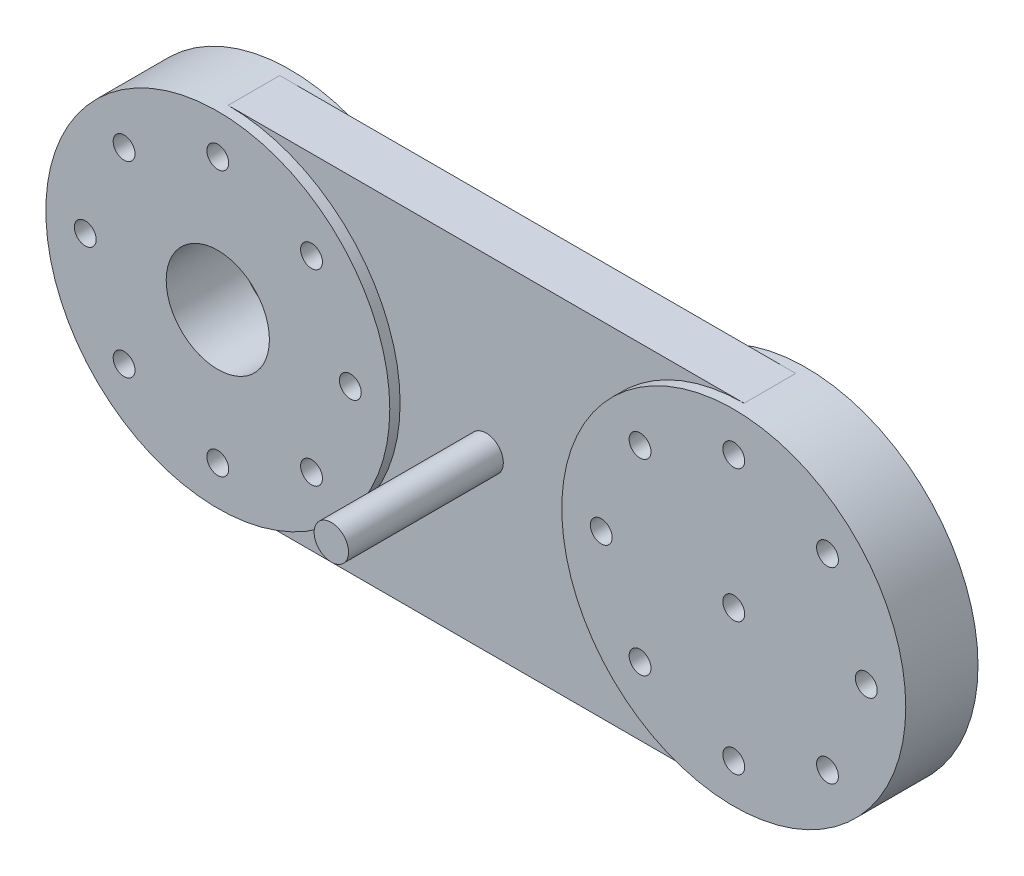
from build123d import *

# Parameters (mm, degrees)
SKETCH_1_W               = 150
SKETCH_1_H               = 100
SHORT_ARM_BODY_DEPTH     = 15
SKETCH_1_17_R            = 5
EXTRUDE_8_DEPTH          = 45
SKETCH_1_30_R            = 50
SKETCH_1_30_R_2          = 3.175
EXTRUDE_10_DEPTH         = 3
SKETCH_1_31_R            = 50
CUT_EXTRUDE_1_DEPTH      = 88
CUT_EXTRUDE_1_DEPTH_BACK = 59
SKETCH_1_33_R            = 50
SKETCH_1_33_R_2          = 3.175
EXTRUDE_12_DEPTH         = 3
EXTRUDE_12_DEPTH_BACK    = 18
SKETCH_3_R               = 15
CUT_EXTRUDE_3_DEPTH      = 98


with BuildPart() as part:
    # Sketch 1 → short_arm_body (new body)
    with BuildSketch(Plane.XY):
        with Locations((-75, 50)):
            Rectangle(SKETCH_1_W, SKETCH_1_H)
    extrude(amount=-SHORT_ARM_BODY_DEPTH)

    # Sketch 1_17 → Extrude 8 (add)
    with BuildSketch(Plane.XY):
        with Locations((-75, 50)):
            Circle(SKETCH_1_17_R)
    extrude(amount=EXTRUDE_8_DEPTH)

    # Sketch 1_30 → Extrude 10 (add)
    with BuildSketch(Plane.XY):
        with Locations((0, 50)):
            Circle(SKETCH_1_30_R)
        with Locations((0, 11.469660941)):
            Circle(SKETCH_1_30_R_2, mode=Mode.SUBTRACT)
        with BuildLine():
            Line((0, 25), (0, 46.825))
            ThreePointArc((0, 46.825), (-2.24506403, 47.75493597), (-3.175, 50))
            Line((-3.175, 50), (-25, 50))
            ThreePointArc((-25, 50), (17.67766953, 67.67766953), (0, 25))
        make_face(mode=Mode.SUBTRACT)
        with Locations((0, 88.530339059)):
            Circle(SKETCH_1_30_R_2, mode=Mode.SUBTRACT)
        with Locations((-38.530339059, 50)):
            Circle(SKETCH_1_30_R_2, mode=Mode.SUBTRACT)
        with Locations((-27.24506403, 77.24506403)):
            Circle(SKETCH_1_30_R_2, mode=Mode.SUBTRACT)
        with Locations((-27.24506403, 22.75493597)):
            Circle(SKETCH_1_30_R_2, mode=Mode.SUBTRACT)
        with Locations((27.24506403, 77.24506403)):
            Circle(SKETCH_1_30_R_2, mode=Mode.SUBTRACT)
        with Locations((38.530339059, 50)):
            Circle(SKETCH_1_30_R_2, mode=Mode.SUBTRACT)
        with Locations((27.24506403, 22.75493597)):
            Circle(SKETCH_1_30_R_2, mode=Mode.SUBTRACT)
    extrude(amount=EXTRUDE_10_DEPTH)

    # Sketch 1_31 → Cut-Extrude 1 (cut, two sides)
    with BuildSketch(Plane.XY) as cut_extrude_1_sk:
        with Locations((0, 50)):
            Circle(SKETCH_1_31_R)
        with Locations((-150, 50)):
            Circle(SKETCH_1_31_R)
    extrude(amount=CUT_EXTRUDE_1_DEPTH, mode=Mode.SUBTRACT)
    extrude(cut_extrude_1_sk.sketch, amount=-CUT_EXTRUDE_1_DEPTH_BACK, mode=Mode.SUBTRACT)

    # Sketch 1_33 → Extrude 12 (add, two sides)
    with BuildSketch(Plane.XY) as extrude_12_sk:
        with Locations((0, 50)):
            Circle(SKETCH_1_33_R)
        with Locations((38.530339059, 50)):
            Circle(SKETCH_1_33_R_2, mode=Mode.SUBTRACT)
        with Locations((27.24506403, 22.75493597)):
            Circle(SKETCH_1_33_R_2, mode=Mode.SUBTRACT)
        with Locations((0, 11.469660941)):
            Circle(SKETCH_1_33_R_2, mode=Mode.SUBTRACT)
        with Locations((-27.24506403, 22.75493597)):
            Circle(SKETCH_1_33_R_2, mode=Mode.SUBTRACT)
        with Locations((-38.530339059, 50)):
            Circle(SKETCH_1_33_R_2, mode=Mode.SUBTRACT)
        with Locations((-27.24506403, 77.24506403)):
            Circle(SKETCH_1_33_R_2, mode=Mode.SUBTRACT)
        with Locations((0, 88.530339059)):
            Circle(SKETCH_1_33_R_2, mode=Mode.SUBTRACT)
        with Locations((27.24506403, 77.24506403)):
            Circle(SKETCH_1_33_R_2, mode=Mode.SUBTRACT)
        with Locations((0, 50)):
            Circle(SKETCH_1_33_R_2, mode=Mode.SUBTRACT)
        with Locations((-150, 50)):
            Circle(SKETCH_1_33_R)
        with Locations((-111.469660941, 50)):
            Circle(SKETCH_1_33_R_2, mode=Mode.SUBTRACT)
        with Locations((-122.75493597, 22.75493597)):
            Circle(SKETCH_1_33_R_2, mode=Mode.SUBTRACT)
        with Locations((-150, 11.469660941)):
            Circle(SKETCH_1_33_R_2, mode=Mode.SUBTRACT)
        with Locations((-177.24506403, 22.75493597)):
            Circle(SKETCH_1_33_R_2, mode=Mode.SUBTRACT)
        with Locations((-188.530339059, 50)):
            Circle(SKETCH_1_33_R_2, mode=Mode.SUBTRACT)
        with Locations((-177.24506403, 77.24506403)):
            Circle(SKETCH_1_33_R_2, mode=Mode.SUBTRACT)
        with Locations((-150, 88.530339059)):
            Circle(SKETCH_1_33_R_2, mode=Mode.SUBTRACT)
        with Locations((-122.75493597, 77.24506403)):
            Circle(SKETCH_1_33_R_2, mode=Mode.SUBTRACT)
        with Locations((-150, 50)):
            Circle(SKETCH_1_33_R_2, mode=Mode.SUBTRACT)
    extrude(amount=EXTRUDE_12_DEPTH)
    extrude(extrude_12_sk.sketch, amount=-EXTRUDE_12_DEPTH_BACK)

    # Sketch 3 → Cut-Extrude 3 (cut)
    with BuildSketch(Plane(origin=(0, 0, -18), x_dir=(-1, 0, 0), z_dir=(0, 0, -1))):
        with Locations((150, 50)):
            Circle(SKETCH_3_R)
    extrude(amount=-CUT_EXTRUDE_3_DEPTH, mode=Mode.SUBTRACT)


solid = part.part
